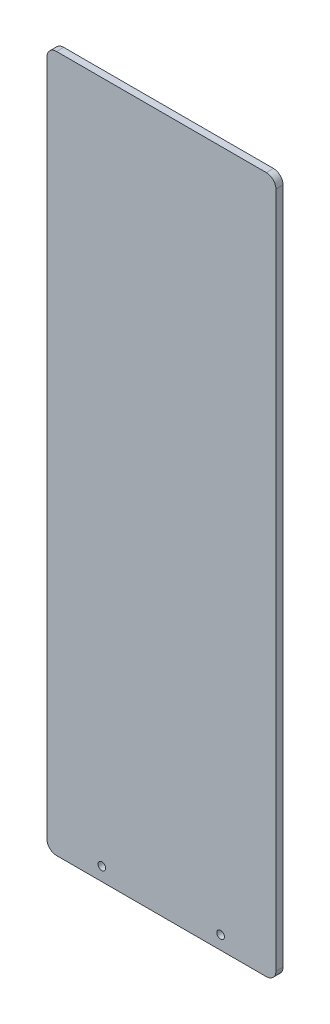
from build123d import *

# Parameters (mm, degrees)
SKETCH1_W           = 152.4
SKETCH1_H           = 463.55
BOSS_EXTRUDE1_DEPTH = 4.7625
FILLET1_R           = 6.35
SKETCH2_R           = 2.54
CUT_EXTRUDE1_DEPTH  = 7.62


with BuildPart() as part:
    # Sketch1 → Boss-Extrude1 (new body)
    with BuildSketch(Plane.XY):
        with Locations((76.2, 231.775)):
            Rectangle(SKETCH1_W, SKETCH1_H)
    extrude(amount=BOSS_EXTRUDE1_DEPTH)

    # Fillet1
    fillet1_edges = [part.edges().sort_by_distance(p)[0] for p in [
        (0, 463.55, 2.38125),
        (152.4, 463.55, 2.38125),
        (152.4, 0, 2.38125),
        (0, 0, 2.38125),
    ]]
    fillet(fillet1_edges, radius=FILLET1_R)

    # Sketch2 → Cut-Extrude1 (cut)
    with BuildSketch(Plane.XY.offset(4.7625)):
        with Locations((115.57, 8.9535)):
            Circle(SKETCH2_R)
        with Locations((36.532989097, 8.9535)):
            Circle(SKETCH2_R)
    extrude(amount=-CUT_EXTRUDE1_DEPTH, mode=Mode.SUBTRACT)


solid = part.part
